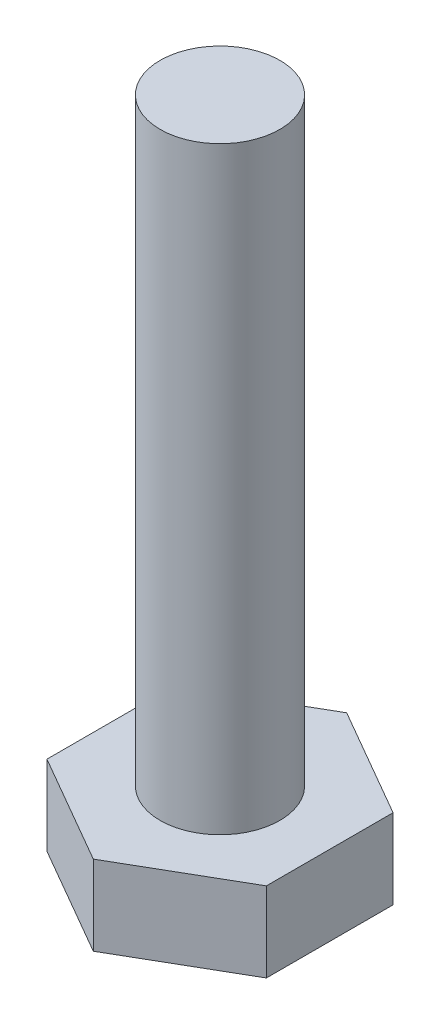
from build123d import *

# Parameters (mm, degrees)
EXTRUDE_1_DEPTH = 2
SKETCH_2_R      = 1.5
EXTRUDE_2_DEPTH = 15


with BuildPart() as part:
    # Эскиз1 → Бобышка-Вытянуть1 (new body)
    with BuildSketch(Plane(origin=(0, 0, 0), x_dir=(1, 0, 0), z_dir=(0, 1, 0))):
        Polygon((0, 3.175426481), (-2.75, 1.58771324), (-2.75, -1.58771324), (0, -3.175426481), (2.75, -1.58771324), (2.75, 1.58771324), align=None)
    extrude(amount=EXTRUDE_1_DEPTH)

    # Эскиз2 → Бобышка-Вытянуть2 (add)
    with BuildSketch(Plane(origin=(0, 2, 0), x_dir=(1, 0, 0), z_dir=(0, 1, 0))):
        Circle(SKETCH_2_R)
    extrude(amount=EXTRUDE_2_DEPTH)


solid = part.part
